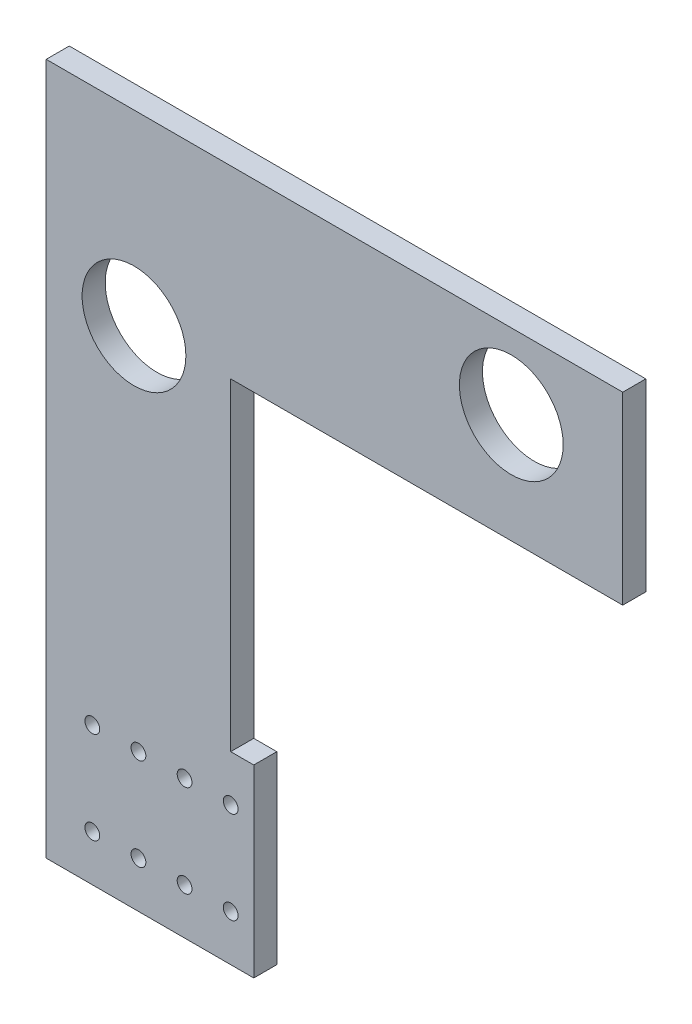
from build123d import *

# Parameters (mm, degrees)
BOSS_EXTRUDE1_DEPTH = 6.35
SKETCH3_R           = 14.2875
SKETCH3_R_2         = 2.032
CUT_EXTRUDE1_DEPTH  = 6.35


with BuildPart() as part:
    # Sketch2 → Boss-Extrude1 (new body)
    with BuildSketch(Plane.XY):
        Polygon((-125.79203122, -159.641560721), (-74.99203122, -159.641560721), (-68.64203122, -159.641560721), (-68.64203122, -108.841560721), (-74.99203122, -108.841560721), (-74.99203122, -19.941560721), (32.95796878, -19.941560721), (32.95796878, 30.858439279), (-125.79203122, 30.858439279), (-125.79203122, -140.591560721), align=None)
    extrude(amount=BOSS_EXTRUDE1_DEPTH)

    # Sketch3 → Cut-Extrude1 (cut)
    with BuildSketch(Plane.XY.offset(6.35)):
        with Locations((-101.619115086, -20.612163927)):
            Circle(SKETCH3_R)
        with Locations((2.266884914, 10.121836073)):
            Circle(SKETCH3_R)
        with Locations((-87.69203122, -146.941560721)):
            Circle(SKETCH3_R_2)
        with Locations((-113.09203122, -146.941560721)):
            Circle(SKETCH3_R_2)
        with Locations((-100.39203122, -146.941560721)):
            Circle(SKETCH3_R_2)
        with Locations((-74.99203122, -146.941560721)):
            Circle(SKETCH3_R_2)
        with Locations((-113.09203122, -121.541560721)):
            Circle(SKETCH3_R_2)
        with Locations((-87.69203122, -121.541560721)):
            Circle(SKETCH3_R_2)
        with Locations((-74.99203122, -121.541560721)):
            Circle(SKETCH3_R_2)
        with Locations((-100.39203122, -121.541560721)):
            Circle(SKETCH3_R_2)
    extrude(amount=-CUT_EXTRUDE1_DEPTH, mode=Mode.SUBTRACT)


solid = part.part
